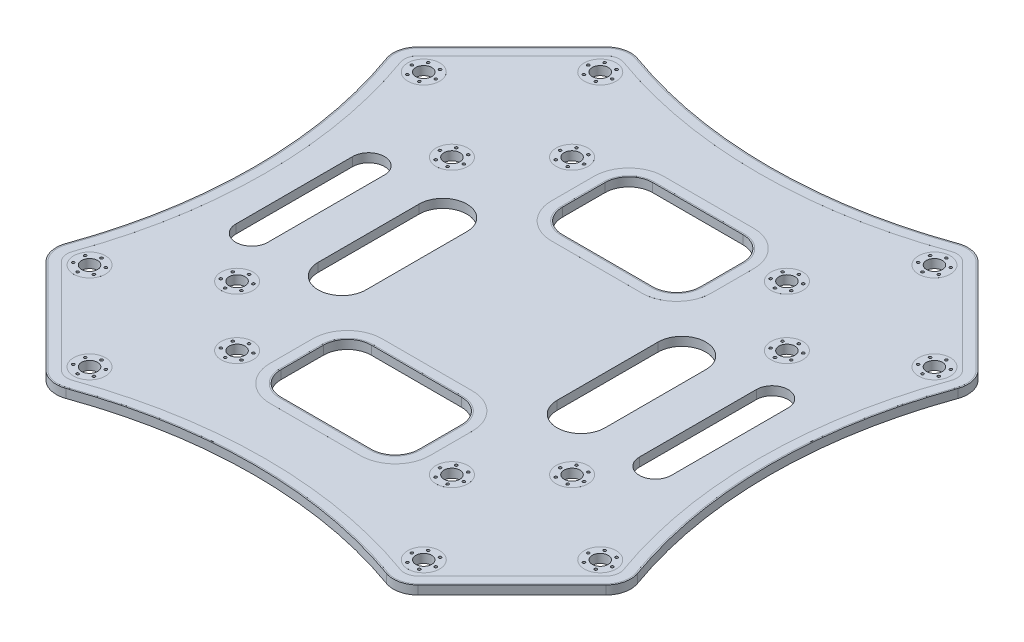
from build123d import *

# Parameters (mm, degrees)
BOSS_EXTRUDE1_DEPTH      = 0.825
BOSS_EXTRUDE1_DEPTH_BACK = 0.825
CUT_EXTRUDE1_DEPTH       = 1.65
SKETCH3_R                = 1.5
CUT_EXTRUDE2_DEPTH       = 1.65
SKETCH4_R                = 3
SKETCH4_R_2              = 1.5
SKETCH4_R_3              = 0.25
BOSS_EXTRUDE2_DEPTH      = 0.001
SKETCH5_R                = 0.25
CUT_EXTRUDE3_DEPTH       = 1.65


with BuildPart() as part:
    # Sketch1 → Boss-Extrude1 (new, two sides)
    with BuildSketch(Plane(origin=(0, 0, 0), x_dir=(1, 0, 0), z_dir=(0, 1, 0))) as boss_extrude1_sk:
        with BuildLine():
            Line((35.046361717, 52.705589829), (52.705589829, 35.046361717))
            ThreePointArc((52.705589829, 35.046361717), (53.961944938, 32.762265708), (53.8, 30.160478519))
            ThreePointArc((53.8, 30.160478519), (48.55, 0), (53.8, -30.160478519))
            ThreePointArc((53.8, -30.160478519), (53.961944938, -32.762265708), (52.705589829, -35.046361717))
            Line((52.705589829, -35.046361717), (35.046361717, -52.705589829))
            ThreePointArc((35.046361717, -52.705589829), (32.762265708, -53.961944938), (30.160478519, -53.8))
            ThreePointArc((30.160478519, -53.8), (0, -48.55), (-30.160478519, -53.8))
            ThreePointArc((-30.160478519, -53.8), (-32.762265708, -53.961944938), (-35.046361717, -52.705589829))
            Line((-35.046361717, -52.705589829), (-52.705589829, -35.046361717))
            ThreePointArc((-52.705589829, -35.046361717), (-53.961944938, -32.762265708), (-53.8, -30.160478519))
            ThreePointArc((-53.8, -30.160478519), (-48.55, 0), (-53.8, 30.160478519))
            ThreePointArc((-53.8, 30.160478519), (-53.961944938, 32.762265708), (-52.705589829, 35.046361717))
            Line((-52.705589829, 35.046361717), (-35.046361717, 52.705589829))
            ThreePointArc((-35.046361717, 52.705589829), (-32.762265708, 53.961944938), (-30.160478519, 53.8))
            ThreePointArc((-30.160478519, 53.8), (0, 48.55), (30.160478519, 53.8))
            ThreePointArc((30.160478519, 53.8), (32.762265708, 53.961944938), (35.046361717, 52.705589829))
        make_face()
    extrude(amount=BOSS_EXTRUDE1_DEPTH)
    extrude(boss_extrude1_sk.sketch, amount=-BOSS_EXTRUDE1_DEPTH_BACK)

    # Sketch2 → Cut-Extrude1 (cut)
    with BuildSketch(Plane(origin=(0, 0.825, 0), x_dir=(1, 0, 0), z_dir=(0, 1, 0))):
        with BuildLine():
            Line((13, 30.5), (13, 22.5))
            ThreePointArc((13, 22.5), (11.681980515, 19.318019485), (8.5, 18))
            Line((8.5, 18), (-8.5, 18))
            ThreePointArc((-8.5, 18), (-11.681980515, 19.318019485), (-13, 22.5))
            Line((-13, 22.5), (-13, 30.5))
            ThreePointArc((-13, 30.5), (-11.681980515, 33.681980515), (-8.5, 35))
            Line((-8.5, 35), (8.5, 35))
            ThreePointArc((8.5, 35), (11.681980515, 33.681980515), (13, 30.5))
        make_face()
        with BuildLine():
            Line((-13, -22.5), (-13, -30.5))
            ThreePointArc((-13, -30.5), (-11.681980515, -33.681980515), (-8.5, -35))
            Line((-8.5, -35), (8.5, -35))
            ThreePointArc((8.5, -35), (11.681980515, -33.681980515), (13, -30.5))
            Line((13, -30.5), (13, -22.5))
            ThreePointArc((13, -22.5), (11.681980515, -19.318019485), (8.5, -18))
            Line((8.5, -18), (-8.5, -18))
            ThreePointArc((-8.5, -18), (-11.681980515, -19.318019485), (-13, -22.5))
        make_face()
        with BuildLine():
            Line((-27, -9.5), (-27, 9.5))
            ThreePointArc((-27, 9.5), (-22.5, 14), (-18, 9.5))
            Line((-18, 9.5), (-18, -9.5))
            ThreePointArc((-18, -9.5), (-22.5, -14), (-27, -9.5))
        make_face()
        with BuildLine():
            Line((18, -9.5), (18, 9.5))
            ThreePointArc((18, 9.5), (22.5, 14), (27, 9.5))
            Line((27, 9.5), (27, -9.5))
            ThreePointArc((27, -9.5), (22.5, -14), (18, -9.5))
        make_face()
        with BuildLine():
            Line((-35, 11), (-35, -11))
            ThreePointArc((-35, -11), (-38, -14), (-41, -11))
            Line((-41, -11), (-41, 11))
            ThreePointArc((-41, 11), (-38, 14), (-35, 11))
        make_face()
        with BuildLine():
            Line((35, 11), (35, -11))
            ThreePointArc((35, -11), (38, -14), (41, -11))
            Line((41, -11), (41, 11))
            ThreePointArc((41, 11), (38, 14), (35, 11))
        make_face()
    extrude(amount=-CUT_EXTRUDE1_DEPTH, mode=Mode.SUBTRACT)

    # Sketch3 → Cut-Extrude2 (cut)
    with BuildSketch(Plane(origin=(0, 0.825, 0), x_dir=(1, 0, 0), z_dir=(0, 1, 0))):
        with Locations(Location((-48.083261121, -31.466251763, 0), (0, 0, 270))):
            Circle(SKETCH3_R)
        with Locations(Location((-31.466251763, -48.083261121, 0), (0, 0, 270))):
            Circle(SKETCH3_R)
        with Locations(Location((31.466251763, -48.083261121, 0), (0, 0, 270))):
            Circle(SKETCH3_R)
        with Locations(Location((48.083261121, -31.466251763, 0), (0, 0, 270))):
            Circle(SKETCH3_R)
        with Locations(Location((48.083261121, 31.466251763, 0), (0, 0, 270))):
            Circle(SKETCH3_R)
        with Locations(Location((31.466251763, 48.083261121, 0), (0, 0, 270))):
            Circle(SKETCH3_R)
        with Locations(Location((-31.466251763, 48.083261121, 0), (0, 0, 270))):
            Circle(SKETCH3_R)
        with Locations(Location((-48.083261121, 31.466251763, 0), (0, 0, 270))):
            Circle(SKETCH3_R)
        with Locations(Location((-31.540291459, -20.22658296, 0), (0, 0, 270))):
            Circle(SKETCH3_R)
        with Locations(Location((-20.22658296, -31.540291459, 0), (0, 0, 270))):
            Circle(SKETCH3_R)
        with Locations(Location((-31.540291459, 20.22658296, 0), (0, 0, 270))):
            Circle(SKETCH3_R)
        with Locations(Location((-20.22658296, 31.540291459, 0), (0, 0, 270))):
            Circle(SKETCH3_R)
        with Locations(Location((20.22658296, 31.540291459, 0), (0, 0, 270))):
            Circle(SKETCH3_R)
        with Locations(Location((31.540291459, 20.22658296, 0), (0, 0, 270))):
            Circle(SKETCH3_R)
        with Locations(Location((31.540291459, -20.22658296, 0), (0, 0, 270))):
            Circle(SKETCH3_R)
        with Locations(Location((20.22658296, -31.540291459, 0), (0, 0, 270))):
            Circle(SKETCH3_R)
    extrude(amount=-CUT_EXTRUDE2_DEPTH, mode=Mode.SUBTRACT)

    # Sketch4 → Boss-Extrude2 (add)
    with BuildSketch(Plane(origin=(0, 0.825, 0), x_dir=(1, 0, 0), z_dir=(0, 1, 0))):
        with BuildLine():
            Line((34.869585021, -52.528813133), (52.528813133, -34.869585021))
            ThreePointArc((52.528813133, -34.869585021), (53.71799007, -32.707621199), (53.564704439, -30.244953362))
            ThreePointArc((53.564704439, -30.244953362), (48.3, 0), (53.564704439, 30.244953362))
            ThreePointArc((53.564704439, 30.244953362), (53.71799007, 32.707621199), (52.528813133, 34.869585021))
            Line((52.528813133, 34.869585021), (34.869585021, 52.528813133))
            ThreePointArc((34.869585021, 52.528813133), (32.707621199, 53.71799007), (30.244953362, 53.564704439))
            ThreePointArc((30.244953362, 53.564704439), (0, 48.3), (-30.244953362, 53.564704439))
            ThreePointArc((-30.244953362, 53.564704439), (-32.707621199, 53.71799007), (-34.869585021, 52.528813133))
            Line((-34.869585021, 52.528813133), (-52.528813133, 34.869585021))
            ThreePointArc((-52.528813133, 34.869585021), (-53.71799007, 32.707621199), (-53.564704439, 30.244953362))
            ThreePointArc((-53.564704439, 30.244953362), (-48.3, 0), (-53.564704439, -30.244953362))
            ThreePointArc((-53.564704439, -30.244953362), (-53.71799007, -32.707621199), (-52.528813133, -34.869585021))
            Line((-52.528813133, -34.869585021), (-34.869585021, -52.528813133))
            ThreePointArc((-34.869585021, -52.528813133), (-32.707621199, -53.71799007), (-30.244953362, -53.564704439))
            ThreePointArc((-30.244953362, -53.564704439), (0, -48.3), (30.244953362, -53.564704439))
            ThreePointArc((30.244953362, -53.564704439), (32.707621199, -53.71799007), (34.869585021, -52.528813133))
        make_face()
        with BuildLine():
            Line((-51.256020927, 33.596792815), (-33.596792815, 51.256020927))
            ThreePointArc((-33.596792815, 51.256020927), (-32.314180733, 51.961515021), (-30.853172233, 51.870576403))
            ThreePointArc((-30.853172233, 51.870576403), (0, 46.5), (30.853172233, 51.870576403))
            ThreePointArc((30.853172233, 51.870576403), (32.314180733, 51.961515021), (33.596792815, 51.256020927))
            Line((33.596792815, 51.256020927), (51.256020927, 33.596792815))
            ThreePointArc((51.256020927, 33.596792815), (51.961515021, 32.314180733), (51.870576403, 30.853172233))
            ThreePointArc((51.870576403, 30.853172233), (46.5, 0), (51.870576403, -30.853172233))
            ThreePointArc((51.870576403, -30.853172233), (51.961515021, -32.314180733), (51.256020927, -33.596792815))
            Line((51.256020927, -33.596792815), (33.596792815, -51.256020927))
            ThreePointArc((33.596792815, -51.256020927), (32.314180733, -51.961515021), (30.853172233, -51.870576403))
            ThreePointArc((30.853172233, -51.870576403), (0, -46.5), (-30.853172233, -51.870576403))
            ThreePointArc((-30.853172233, -51.870576403), (-32.314180733, -51.961515021), (-33.596792815, -51.256020927))
            Line((-33.596792815, -51.256020927), (-51.256020927, -33.596792815))
            ThreePointArc((-51.256020927, -33.596792815), (-51.961515021, -32.314180733), (-51.870576403, -30.853172233))
            ThreePointArc((-51.870576403, -30.853172233), (-46.5, 0), (-51.870576403, 30.853172233))
            ThreePointArc((-51.870576403, 30.853172233), (-51.961515021, 32.314180733), (-51.256020927, 33.596792815))
        make_face(mode=Mode.SUBTRACT)
        with BuildLine():
            Line((15.05, 30.5), (15.05, 22.5))
            ThreePointArc((15.05, 22.5), (13.131549417, 17.868450583), (8.5, 15.95))
            Line((8.5, 15.95), (-8.5, 15.95))
            ThreePointArc((-8.5, 15.95), (-13.131549417, 17.868450583), (-15.05, 22.5))
            Line((-15.05, 22.5), (-15.05, 30.5))
            ThreePointArc((-15.05, 30.5), (-13.131549417, 35.131549417), (-8.5, 37.05))
            Line((-8.5, 37.05), (8.5, 37.05))
            ThreePointArc((8.5, 37.05), (13.131549417, 35.131549417), (15.05, 30.5))
        make_face()
        with BuildLine():
            Line((-8.5, 17.75), (8.5, 17.75))
            ThreePointArc((8.5, 17.75), (11.858757211, 19.141242789), (13.25, 22.5))
            Line((13.25, 22.5), (13.25, 30.5))
            ThreePointArc((13.25, 30.5), (11.858757211, 33.858757211), (8.5, 35.25))
            Line((8.5, 35.25), (-8.5, 35.25))
            ThreePointArc((-8.5, 35.25), (-11.858757211, 33.858757211), (-13.25, 30.5))
            Line((-13.25, 30.5), (-13.25, 22.5))
            ThreePointArc((-13.25, 22.5), (-11.858757211, 19.141242789), (-8.5, 17.75))
        make_face(mode=Mode.SUBTRACT)
        with BuildLine():
            Line((15.05, -30.5), (15.05, -22.5))
            ThreePointArc((15.05, -22.5), (13.131549417, -17.868450583), (8.5, -15.95))
            Line((8.5, -15.95), (-8.5, -15.95))
            ThreePointArc((-8.5, -15.95), (-13.131549417, -17.868450583), (-15.05, -22.5))
            Line((-15.05, -22.5), (-15.05, -30.5))
            ThreePointArc((-15.05, -30.5), (-13.131549417, -35.131549417), (-8.5, -37.05))
            Line((-8.5, -37.05), (8.5, -37.05))
            ThreePointArc((8.5, -37.05), (13.131549417, -35.131549417), (15.05, -30.5))
        make_face()
        with BuildLine():
            Line((13.25, -30.5), (13.25, -22.5))
            ThreePointArc((13.25, -22.5), (11.858757211, -19.141242789), (8.5, -17.75))
            Line((8.5, -17.75), (-8.5, -17.75))
            ThreePointArc((-8.5, -17.75), (-11.858757211, -19.141242789), (-13.25, -22.5))
            Line((-13.25, -22.5), (-13.25, -30.5))
            ThreePointArc((-13.25, -30.5), (-11.858757211, -33.858757211), (-8.5, -35.25))
            Line((-8.5, -35.25), (8.5, -35.25))
            ThreePointArc((8.5, -35.25), (11.858757211, -33.858757211), (13.25, -30.5))
        make_face(mode=Mode.SUBTRACT)
        with Locations(Location((31.466251763, -48.083261121, 0), (0, 0, 270))):
            Circle(SKETCH4_R)
        with Locations(Location((31.466251763, -48.083261121, 0), (0, 0, 270))):
            Circle(SKETCH4_R_2, mode=Mode.SUBTRACT)
        with Locations(Location((30.341251763, -50.031818279, 0), (0, 0, 270))):
            Circle(SKETCH4_R_3, mode=Mode.SUBTRACT)
        with Locations(Location((29.216251763, -48.083261121, 0), (0, 0, 270))):
            Circle(SKETCH4_R_3, mode=Mode.SUBTRACT)
        with Locations(Location((30.341251763, -46.134703962, 0), (0, 0, 270))):
            Circle(SKETCH4_R_3, mode=Mode.SUBTRACT)
        with Locations(Location((32.591251763, -46.134703962, 0), (0, 0, 270))):
            Circle(SKETCH4_R_3, mode=Mode.SUBTRACT)
        with Locations(Location((33.716251763, -48.083261121, 0), (0, 0, 270))):
            Circle(SKETCH4_R_3, mode=Mode.SUBTRACT)
        with Locations(Location((32.591251763, -50.031818279, 0), (0, 0, 270))):
            Circle(SKETCH4_R_3, mode=Mode.SUBTRACT)
        with Locations(Location((48.083261121, -31.466251763, 0), (0, 0, 270))):
            Circle(SKETCH4_R)
        with Locations(Location((48.083261121, -31.466251763, 0), (0, 0, 270))):
            Circle(SKETCH4_R_2, mode=Mode.SUBTRACT)
        with Locations(Location((46.958261121, -33.414808921, 0), (0, 0, 270))):
            Circle(SKETCH4_R_3, mode=Mode.SUBTRACT)
        with Locations(Location((45.833261121, -31.466251763, 0), (0, 0, 270))):
            Circle(SKETCH4_R_3, mode=Mode.SUBTRACT)
        with Locations(Location((46.958261121, -29.517694604, 0), (0, 0, 270))):
            Circle(SKETCH4_R_3, mode=Mode.SUBTRACT)
        with Locations(Location((49.208261121, -29.517694604, 0), (0, 0, 270))):
            Circle(SKETCH4_R_3, mode=Mode.SUBTRACT)
        with Locations(Location((50.333261121, -31.466251763, 0), (0, 0, 270))):
            Circle(SKETCH4_R_3, mode=Mode.SUBTRACT)
        with Locations(Location((49.208261121, -33.414808921, 0), (0, 0, 270))):
            Circle(SKETCH4_R_3, mode=Mode.SUBTRACT)
        with Locations(Location((31.540291459, -20.22658296, 0), (0, 0, 270))):
            Circle(SKETCH4_R)
        with Locations(Location((31.540291459, -20.22658296, 0), (0, 0, 270))):
            Circle(SKETCH4_R_2, mode=Mode.SUBTRACT)
        with Locations(Location((30.415291459, -22.175140119, 0), (0, 0, 270))):
            Circle(SKETCH4_R_3, mode=Mode.SUBTRACT)
        with Locations(Location((29.290291459, -20.22658296, 0), (0, 0, 270))):
            Circle(SKETCH4_R_3, mode=Mode.SUBTRACT)
        with Locations(Location((30.415291459, -18.278025802, 0), (0, 0, 270))):
            Circle(SKETCH4_R_3, mode=Mode.SUBTRACT)
        with Locations(Location((32.665291459, -18.278025802, 0), (0, 0, 270))):
            Circle(SKETCH4_R_3, mode=Mode.SUBTRACT)
        with Locations(Location((33.790291459, -20.22658296, 0), (0, 0, 270))):
            Circle(SKETCH4_R_3, mode=Mode.SUBTRACT)
        with Locations(Location((32.665291459, -22.175140119, 0), (0, 0, 270))):
            Circle(SKETCH4_R_3, mode=Mode.SUBTRACT)
        with Locations(Location((20.22658296, -31.540291459, 0), (0, 0, 270))):
            Circle(SKETCH4_R)
        with Locations(Location((20.22658296, -31.540291459, 0), (0, 0, 270))):
            Circle(SKETCH4_R_2, mode=Mode.SUBTRACT)
        with Locations(Location((19.10158296, -33.488848618, 0), (0, 0, 270))):
            Circle(SKETCH4_R_3, mode=Mode.SUBTRACT)
        with Locations(Location((21.35158296, -33.488848618, 0), (0, 0, 270))):
            Circle(SKETCH4_R_3, mode=Mode.SUBTRACT)
        with Locations(Location((22.47658296, -31.540291459, 0), (0, 0, 270))):
            Circle(SKETCH4_R_3, mode=Mode.SUBTRACT)
        with Locations(Location((21.35158296, -29.591734301, 0), (0, 0, 270))):
            Circle(SKETCH4_R_3, mode=Mode.SUBTRACT)
        with Locations(Location((19.10158296, -29.591734301, 0), (0, 0, 270))):
            Circle(SKETCH4_R_3, mode=Mode.SUBTRACT)
        with Locations(Location((17.97658296, -31.540291459, 0), (0, 0, 270))):
            Circle(SKETCH4_R_3, mode=Mode.SUBTRACT)
        with Locations(Location((31.540291459, 20.22658296, 0), (0, 0, 270))):
            Circle(SKETCH4_R)
        with Locations(Location((31.540291459, 20.22658296, 0), (0, 0, 270))):
            Circle(SKETCH4_R_2, mode=Mode.SUBTRACT)
        with Locations(Location((29.591734301, 21.35158296, 0), (0, 0, 270))):
            Circle(SKETCH4_R_3, mode=Mode.SUBTRACT)
        with Locations(Location((29.591734301, 19.10158296, 0), (0, 0, 270))):
            Circle(SKETCH4_R_3, mode=Mode.SUBTRACT)
        with Locations(Location((31.540291459, 17.97658296, 0), (0, 0, 270))):
            Circle(SKETCH4_R_3, mode=Mode.SUBTRACT)
        with Locations(Location((33.488848618, 19.10158296, 0), (0, 0, 270))):
            Circle(SKETCH4_R_3, mode=Mode.SUBTRACT)
        with Locations(Location((33.488848618, 21.35158296, 0), (0, 0, 270))):
            Circle(SKETCH4_R_3, mode=Mode.SUBTRACT)
        with Locations(Location((31.540291459, 22.47658296, 0), (0, 0, 270))):
            Circle(SKETCH4_R_3, mode=Mode.SUBTRACT)
        with Locations(Location((48.083261121, 31.466251763, 0), (0, 0, 270))):
            Circle(SKETCH4_R)
        with Locations(Location((48.083261121, 31.466251763, 0), (0, 0, 270))):
            Circle(SKETCH4_R_2, mode=Mode.SUBTRACT)
        with Locations(Location((48.083261121, 29.216251763, 0), (0, 0, 270))):
            Circle(SKETCH4_R_3, mode=Mode.SUBTRACT)
        with Locations(Location((46.134703962, 30.341251763, 0), (0, 0, 270))):
            Circle(SKETCH4_R_3, mode=Mode.SUBTRACT)
        with Locations(Location((50.031818279, 30.341251763, 0), (0, 0, 270))):
            Circle(SKETCH4_R_3, mode=Mode.SUBTRACT)
        with Locations(Location((50.031818279, 32.591251763, 0), (0, 0, 270))):
            Circle(SKETCH4_R_3, mode=Mode.SUBTRACT)
        with Locations(Location((48.083261121, 33.716251763, 0), (0, 0, 270))):
            Circle(SKETCH4_R_3, mode=Mode.SUBTRACT)
        with Locations(Location((46.134703962, 32.591251763, 0), (0, 0, 270))):
            Circle(SKETCH4_R_3, mode=Mode.SUBTRACT)
        with Locations(Location((31.466251763, 48.083261121, 0), (0, 0, 270))):
            Circle(SKETCH4_R)
        with Locations(Location((31.466251763, 48.083261121, 0), (0, 0, 270))):
            Circle(SKETCH4_R_2, mode=Mode.SUBTRACT)
        with Locations(Location((31.466251763, 45.833261121, 0), (0, 0, 270))):
            Circle(SKETCH4_R_3, mode=Mode.SUBTRACT)
        with Locations(Location((29.517694604, 46.958261121, 0), (0, 0, 270))):
            Circle(SKETCH4_R_3, mode=Mode.SUBTRACT)
        with Locations(Location((29.517694604, 49.208261121, 0), (0, 0, 270))):
            Circle(SKETCH4_R_3, mode=Mode.SUBTRACT)
        with Locations(Location((31.466251763, 50.333261121, 0), (0, 0, 270))):
            Circle(SKETCH4_R_3, mode=Mode.SUBTRACT)
        with Locations(Location((33.414808921, 49.208261121, 0), (0, 0, 270))):
            Circle(SKETCH4_R_3, mode=Mode.SUBTRACT)
        with Locations(Location((33.414808921, 46.958261121, 0), (0, 0, 270))):
            Circle(SKETCH4_R_3, mode=Mode.SUBTRACT)
        with Locations(Location((20.22658296, 31.540291459, 0), (0, 0, 270))):
            Circle(SKETCH4_R)
        with Locations(Location((20.22658296, 31.540291459, 0), (0, 0, 270))):
            Circle(SKETCH4_R_2, mode=Mode.SUBTRACT)
        with Locations(Location((20.22658296, 29.290291459, 0), (0, 0, 270))):
            Circle(SKETCH4_R_3, mode=Mode.SUBTRACT)
        with Locations(Location((22.175140119, 30.415291459, 0), (0, 0, 270))):
            Circle(SKETCH4_R_3, mode=Mode.SUBTRACT)
        with Locations(Location((22.175140119, 32.665291459, 0), (0, 0, 270))):
            Circle(SKETCH4_R_3, mode=Mode.SUBTRACT)
        with Locations(Location((18.278025802, 30.415291459, 0), (0, 0, 270))):
            Circle(SKETCH4_R_3, mode=Mode.SUBTRACT)
        with Locations(Location((18.278025802, 32.665291459, 0), (0, 0, 270))):
            Circle(SKETCH4_R_3, mode=Mode.SUBTRACT)
        with Locations(Location((20.22658296, 33.790291459, 0), (0, 0, 270))):
            Circle(SKETCH4_R_3, mode=Mode.SUBTRACT)
        with Locations(Location((-31.466251763, 48.083261121, 0), (0, 0, 270))):
            Circle(SKETCH4_R)
        with Locations(Location((-31.466251763, 48.083261121, 0), (0, 0, 270))):
            Circle(SKETCH4_R_2, mode=Mode.SUBTRACT)
        with Locations(Location((-32.591251763, 46.134703962, 0), (0, 0, 270))):
            Circle(SKETCH4_R_3, mode=Mode.SUBTRACT)
        with Locations(Location((-33.716251763, 48.083261121, 0), (0, 0, 270))):
            Circle(SKETCH4_R_3, mode=Mode.SUBTRACT)
        with Locations(Location((-32.591251763, 50.031818279, 0), (0, 0, 270))):
            Circle(SKETCH4_R_3, mode=Mode.SUBTRACT)
        with Locations(Location((-30.341251763, 50.031818279, 0), (0, 0, 270))):
            Circle(SKETCH4_R_3, mode=Mode.SUBTRACT)
        with Locations(Location((-29.216251763, 48.083261121, 0), (0, 0, 270))):
            Circle(SKETCH4_R_3, mode=Mode.SUBTRACT)
        with Locations(Location((-30.341251763, 46.134703962, 0), (0, 0, 270))):
            Circle(SKETCH4_R_3, mode=Mode.SUBTRACT)
        with Locations(Location((-20.22658296, 31.540291459, 0), (0, 0, 270))):
            Circle(SKETCH4_R)
        with Locations(Location((-20.22658296, 31.540291459, 0), (0, 0, 270))):
            Circle(SKETCH4_R_2, mode=Mode.SUBTRACT)
        with Locations(Location((-19.10158296, 29.591734301, 0), (0, 0, 270))):
            Circle(SKETCH4_R_3, mode=Mode.SUBTRACT)
        with Locations(Location((-21.35158296, 29.591734301, 0), (0, 0, 270))):
            Circle(SKETCH4_R_3, mode=Mode.SUBTRACT)
        with Locations(Location((-22.47658296, 31.540291459, 0), (0, 0, 270))):
            Circle(SKETCH4_R_3, mode=Mode.SUBTRACT)
        with Locations(Location((-21.35158296, 33.488848618, 0), (0, 0, 270))):
            Circle(SKETCH4_R_3, mode=Mode.SUBTRACT)
        with Locations(Location((-19.10158296, 33.488848618, 0), (0, 0, 270))):
            Circle(SKETCH4_R_3, mode=Mode.SUBTRACT)
        with Locations(Location((-17.97658296, 31.540291459, 0), (0, 0, 270))):
            Circle(SKETCH4_R_3, mode=Mode.SUBTRACT)
        with Locations(Location((-31.540291459, 20.22658296, 0), (0, 0, 270))):
            Circle(SKETCH4_R)
        with Locations(Location((-31.540291459, 20.22658296, 0), (0, 0, 270))):
            Circle(SKETCH4_R_2, mode=Mode.SUBTRACT)
        with Locations(Location((-32.665291459, 18.278025802, 0), (0, 0, 270))):
            Circle(SKETCH4_R_3, mode=Mode.SUBTRACT)
        with Locations(Location((-33.790291459, 20.22658296, 0), (0, 0, 270))):
            Circle(SKETCH4_R_3, mode=Mode.SUBTRACT)
        with Locations(Location((-32.665291459, 22.175140119, 0), (0, 0, 270))):
            Circle(SKETCH4_R_3, mode=Mode.SUBTRACT)
        with Locations(Location((-30.415291459, 22.175140119, 0), (0, 0, 270))):
            Circle(SKETCH4_R_3, mode=Mode.SUBTRACT)
        with Locations(Location((-29.290291459, 20.22658296, 0), (0, 0, 270))):
            Circle(SKETCH4_R_3, mode=Mode.SUBTRACT)
        with Locations(Location((-30.415291459, 18.278025802, 0), (0, 0, 270))):
            Circle(SKETCH4_R_3, mode=Mode.SUBTRACT)
        with Locations(Location((-48.083261121, 31.466251763, 0), (0, 0, 270))):
            Circle(SKETCH4_R)
        with Locations(Location((-48.083261121, 31.466251763, 0), (0, 0, 270))):
            Circle(SKETCH4_R_2, mode=Mode.SUBTRACT)
        with Locations(Location((-46.958261121, 29.517694604, 0), (0, 0, 270))):
            Circle(SKETCH4_R_3, mode=Mode.SUBTRACT)
        with Locations(Location((-45.833261121, 31.466251763, 0), (0, 0, 270))):
            Circle(SKETCH4_R_3, mode=Mode.SUBTRACT)
        with Locations(Location((-46.958261121, 33.414808921, 0), (0, 0, 270))):
            Circle(SKETCH4_R_3, mode=Mode.SUBTRACT)
        with Locations(Location((-49.208261121, 33.414808921, 0), (0, 0, 270))):
            Circle(SKETCH4_R_3, mode=Mode.SUBTRACT)
        with Locations(Location((-50.333261121, 31.466251763, 0), (0, 0, 270))):
            Circle(SKETCH4_R_3, mode=Mode.SUBTRACT)
        with Locations(Location((-49.208261121, 29.517694604, 0), (0, 0, 270))):
            Circle(SKETCH4_R_3, mode=Mode.SUBTRACT)
        with Locations(Location((-20.22658296, -31.540291459, 0), (0, 0, 270))):
            Circle(SKETCH4_R)
        with Locations(Location((-20.22658296, -31.540291459, 0), (0, 0, 270))):
            Circle(SKETCH4_R_2, mode=Mode.SUBTRACT)
        with Locations(Location((-20.22658296, -33.790291459, 0), (0, 0, 270))):
            Circle(SKETCH4_R_3, mode=Mode.SUBTRACT)
        with Locations(Location((-18.278025802, -32.665291459, 0), (0, 0, 270))):
            Circle(SKETCH4_R_3, mode=Mode.SUBTRACT)
        with Locations(Location((-18.278025802, -30.415291459, 0), (0, 0, 270))):
            Circle(SKETCH4_R_3, mode=Mode.SUBTRACT)
        with Locations(Location((-20.22658296, -29.290291459, 0), (0, 0, 270))):
            Circle(SKETCH4_R_3, mode=Mode.SUBTRACT)
        with Locations(Location((-22.175140119, -30.415291459, 0), (0, 0, 270))):
            Circle(SKETCH4_R_3, mode=Mode.SUBTRACT)
        with Locations(Location((-22.175140119, -32.665291459, 0), (0, 0, 270))):
            Circle(SKETCH4_R_3, mode=Mode.SUBTRACT)
        with Locations(Location((-31.540291459, -20.22658296, 0), (0, 0, 270))):
            Circle(SKETCH4_R)
        with Locations(Location((-31.540291459, -20.22658296, 0), (0, 0, 270))):
            Circle(SKETCH4_R_2, mode=Mode.SUBTRACT)
        with Locations(Location((-31.540291459, -22.47658296, 0), (0, 0, 270))):
            Circle(SKETCH4_R_3, mode=Mode.SUBTRACT)
        with Locations(Location((-29.591734301, -21.35158296, 0), (0, 0, 270))):
            Circle(SKETCH4_R_3, mode=Mode.SUBTRACT)
        with Locations(Location((-29.591734301, -19.10158296, 0), (0, 0, 270))):
            Circle(SKETCH4_R_3, mode=Mode.SUBTRACT)
        with Locations(Location((-31.540291459, -17.97658296, 0), (0, 0, 270))):
            Circle(SKETCH4_R_3, mode=Mode.SUBTRACT)
        with Locations(Location((-33.488848618, -19.10158296, 0), (0, 0, 270))):
            Circle(SKETCH4_R_3, mode=Mode.SUBTRACT)
        with Locations(Location((-33.488848618, -21.35158296, 0), (0, 0, 270))):
            Circle(SKETCH4_R_3, mode=Mode.SUBTRACT)
        with Locations(Location((-48.083261121, -31.466251763, 0), (0, 0, 270))):
            Circle(SKETCH4_R)
        with Locations(Location((-48.083261121, -31.466251763, 0), (0, 0, 270))):
            Circle(SKETCH4_R_2, mode=Mode.SUBTRACT)
        with Locations(Location((-48.083261121, -33.716251763, 0), (0, 0, 270))):
            Circle(SKETCH4_R_3, mode=Mode.SUBTRACT)
        with Locations(Location((-46.134703962, -32.591251763, 0), (0, 0, 270))):
            Circle(SKETCH4_R_3, mode=Mode.SUBTRACT)
        with Locations(Location((-46.134703962, -30.341251763, 0), (0, 0, 270))):
            Circle(SKETCH4_R_3, mode=Mode.SUBTRACT)
        with Locations(Location((-48.083261121, -29.216251763, 0), (0, 0, 270))):
            Circle(SKETCH4_R_3, mode=Mode.SUBTRACT)
        with Locations(Location((-50.031818279, -30.341251763, 0), (0, 0, 270))):
            Circle(SKETCH4_R_3, mode=Mode.SUBTRACT)
        with Locations(Location((-50.031818279, -32.591251763, 0), (0, 0, 270))):
            Circle(SKETCH4_R_3, mode=Mode.SUBTRACT)
        with Locations(Location((-31.466251763, -48.083261121, 0), (0, 0, 270))):
            Circle(SKETCH4_R)
        with Locations(Location((-31.466251763, -48.083261121, 0), (0, 0, 270))):
            Circle(SKETCH4_R_2, mode=Mode.SUBTRACT)
        with Locations(Location((-31.466251763, -50.333261121, 0), (0, 0, 270))):
            Circle(SKETCH4_R_3, mode=Mode.SUBTRACT)
        with Locations(Location((-29.517694604, -49.208261121, 0), (0, 0, 270))):
            Circle(SKETCH4_R_3, mode=Mode.SUBTRACT)
        with Locations(Location((-29.517694604, -46.958261121, 0), (0, 0, 270))):
            Circle(SKETCH4_R_3, mode=Mode.SUBTRACT)
        with Locations(Location((-31.466251763, -45.833261121, 0), (0, 0, 270))):
            Circle(SKETCH4_R_3, mode=Mode.SUBTRACT)
        with Locations(Location((-33.414808921, -46.958261121, 0), (0, 0, 270))):
            Circle(SKETCH4_R_3, mode=Mode.SUBTRACT)
        with Locations(Location((-33.414808921, -49.208261121, 0), (0, 0, 270))):
            Circle(SKETCH4_R_3, mode=Mode.SUBTRACT)
    boss_extrude2 = extrude(amount=BOSS_EXTRUDE2_DEPTH)

    # Mirror2: Boss-Extrude2 across plane
    add(boss_extrude2.mirror(Plane.ZX))

    # Sketch5 → Cut-Extrude3 (cut)
    with BuildSketch(Plane(origin=(0, 0.825, 0), x_dir=(1, 0, 0), z_dir=(0, 1, 0))):
        with Locations(Location((-31.466251763, -45.833261121, 0), (0, 0, 270))):
            Circle(SKETCH5_R)
        with Locations(Location((-29.517694604, -46.958261121, 0), (0, 0, 270))):
            Circle(SKETCH5_R)
        with Locations(Location((-29.517694604, -49.208261121, 0), (0, 0, 270))):
            Circle(SKETCH5_R)
        with Locations(Location((-31.466251763, -50.333261121, 0), (0, 0, 270))):
            Circle(SKETCH5_R)
        with Locations(Location((-33.414808921, -49.208261121, 0), (0, 0, 270))):
            Circle(SKETCH5_R)
        with Locations(Location((-33.414808921, -46.958261121, 0), (0, 0, 270))):
            Circle(SKETCH5_R)
        with Locations(Location((-48.083261121, -33.716251763, 0), (0, 0, 270))):
            Circle(SKETCH5_R)
        with Locations(Location((-50.031818279, -32.591251763, 0), (0, 0, 270))):
            Circle(SKETCH5_R)
        with Locations(Location((-50.031818279, -30.341251763, 0), (0, 0, 270))):
            Circle(SKETCH5_R)
        with Locations(Location((-48.083261121, -29.216251763, 0), (0, 0, 270))):
            Circle(SKETCH5_R)
        with Locations(Location((-46.134703962, -30.341251763, 0), (0, 0, 270))):
            Circle(SKETCH5_R)
        with Locations(Location((-46.134703962, -32.591251763, 0), (0, 0, 270))):
            Circle(SKETCH5_R)
        with Locations(Location((-33.488848618, -21.35158296, 0), (0, 0, 270))):
            Circle(SKETCH5_R)
        with Locations(Location((-33.488848618, -19.10158296, 0), (0, 0, 270))):
            Circle(SKETCH5_R)
        with Locations(Location((-31.540291459, -17.97658296, 0), (0, 0, 270))):
            Circle(SKETCH5_R)
        with Locations(Location((-29.591734301, -19.10158296, 0), (0, 0, 270))):
            Circle(SKETCH5_R)
        with Locations(Location((-29.591734301, -21.35158296, 0), (0, 0, 270))):
            Circle(SKETCH5_R)
        with Locations(Location((-31.540291459, -22.47658296, 0), (0, 0, 270))):
            Circle(SKETCH5_R)
        with Locations(Location((-22.175140119, -30.415291459, 0), (0, 0, 270))):
            Circle(SKETCH5_R)
        with Locations(Location((-22.175140119, -32.665291459, 0), (0, 0, 270))):
            Circle(SKETCH5_R)
        with Locations(Location((-20.22658296, -33.790291459, 0), (0, 0, 270))):
            Circle(SKETCH5_R)
        with Locations(Location((-18.278025802, -32.665291459, 0), (0, 0, 270))):
            Circle(SKETCH5_R)
        with Locations(Location((-18.278025802, -30.415291459, 0), (0, 0, 270))):
            Circle(SKETCH5_R)
        with Locations(Location((-20.22658296, -29.290291459, 0), (0, 0, 270))):
            Circle(SKETCH5_R)
        with Locations(Location((19.10158296, -33.488848618, 0), (0, 0, 270))):
            Circle(SKETCH5_R)
        with Locations(Location((17.97658296, -31.540291459, 0), (0, 0, 270))):
            Circle(SKETCH5_R)
        with Locations(Location((19.10158296, -29.591734301, 0), (0, 0, 270))):
            Circle(SKETCH5_R)
        with Locations(Location((21.35158296, -29.591734301, 0), (0, 0, 270))):
            Circle(SKETCH5_R)
        with Locations(Location((22.47658296, -31.540291459, 0), (0, 0, 270))):
            Circle(SKETCH5_R)
        with Locations(Location((21.35158296, -33.488848618, 0), (0, 0, 270))):
            Circle(SKETCH5_R)
        with Locations(Location((29.290291459, -20.22658296, 0), (0, 0, 270))):
            Circle(SKETCH5_R)
        with Locations(Location((30.415291459, -18.278025802, 0), (0, 0, 270))):
            Circle(SKETCH5_R)
        with Locations(Location((32.665291459, -18.278025802, 0), (0, 0, 270))):
            Circle(SKETCH5_R)
        with Locations(Location((30.415291459, -22.175140119, 0), (0, 0, 270))):
            Circle(SKETCH5_R)
        with Locations(Location((32.665291459, -22.175140119, 0), (0, 0, 270))):
            Circle(SKETCH5_R)
        with Locations(Location((33.790291459, -20.22658296, 0), (0, 0, 270))):
            Circle(SKETCH5_R)
        with Locations(Location((46.958261121, -29.517694604, 0), (0, 0, 270))):
            Circle(SKETCH5_R)
        with Locations(Location((49.208261121, -29.517694604, 0), (0, 0, 270))):
            Circle(SKETCH5_R)
        with Locations(Location((45.833261121, -31.466251763, 0), (0, 0, 270))):
            Circle(SKETCH5_R)
        with Locations(Location((46.958261121, -33.414808921, 0), (0, 0, 270))):
            Circle(SKETCH5_R)
        with Locations(Location((49.208261121, -33.414808921, 0), (0, 0, 270))):
            Circle(SKETCH5_R)
        with Locations(Location((50.333261121, -31.466251763, 0), (0, 0, 270))):
            Circle(SKETCH5_R)
        with Locations(Location((30.341251763, -46.134703962, 0), (0, 0, 270))):
            Circle(SKETCH5_R)
        with Locations(Location((32.591251763, -46.134703962, 0), (0, 0, 270))):
            Circle(SKETCH5_R)
        with Locations(Location((29.216251763, -48.083261121, 0), (0, 0, 270))):
            Circle(SKETCH5_R)
        with Locations(Location((30.341251763, -50.031818279, 0), (0, 0, 270))):
            Circle(SKETCH5_R)
        with Locations(Location((32.591251763, -50.031818279, 0), (0, 0, 270))):
            Circle(SKETCH5_R)
        with Locations(Location((33.716251763, -48.083261121, 0), (0, 0, 270))):
            Circle(SKETCH5_R)
        with Locations(Location((-32.665291459, 18.278025802, 0), (0, 0, 270))):
            Circle(SKETCH5_R)
        with Locations(Location((-33.790291459, 20.22658296, 0), (0, 0, 270))):
            Circle(SKETCH5_R)
        with Locations(Location((-32.665291459, 22.175140119, 0), (0, 0, 270))):
            Circle(SKETCH5_R)
        with Locations(Location((-30.415291459, 22.175140119, 0), (0, 0, 270))):
            Circle(SKETCH5_R)
        with Locations(Location((-29.290291459, 20.22658296, 0), (0, 0, 270))):
            Circle(SKETCH5_R)
        with Locations(Location((-30.415291459, 18.278025802, 0), (0, 0, 270))):
            Circle(SKETCH5_R)
        with Locations(Location((-49.208261121, 29.517694604, 0), (0, 0, 270))):
            Circle(SKETCH5_R)
        with Locations(Location((-50.333261121, 31.466251763, 0), (0, 0, 270))):
            Circle(SKETCH5_R)
        with Locations(Location((-49.208261121, 33.414808921, 0), (0, 0, 270))):
            Circle(SKETCH5_R)
        with Locations(Location((-46.958261121, 33.414808921, 0), (0, 0, 270))):
            Circle(SKETCH5_R)
        with Locations(Location((-45.833261121, 31.466251763, 0), (0, 0, 270))):
            Circle(SKETCH5_R)
        with Locations(Location((-46.958261121, 29.517694604, 0), (0, 0, 270))):
            Circle(SKETCH5_R)
        with Locations(Location((-32.591251763, 46.134703962, 0), (0, 0, 270))):
            Circle(SKETCH5_R)
        with Locations(Location((-33.716251763, 48.083261121, 0), (0, 0, 270))):
            Circle(SKETCH5_R)
        with Locations(Location((-32.591251763, 50.031818279, 0), (0, 0, 270))):
            Circle(SKETCH5_R)
        with Locations(Location((-30.341251763, 50.031818279, 0), (0, 0, 270))):
            Circle(SKETCH5_R)
        with Locations(Location((-29.216251763, 48.083261121, 0), (0, 0, 270))):
            Circle(SKETCH5_R)
        with Locations(Location((-30.341251763, 46.134703962, 0), (0, 0, 270))):
            Circle(SKETCH5_R)
        with Locations(Location((-21.35158296, 29.591734301, 0), (0, 0, 270))):
            Circle(SKETCH5_R)
        with Locations(Location((-22.47658296, 31.540291459, 0), (0, 0, 270))):
            Circle(SKETCH5_R)
        with Locations(Location((-21.35158296, 33.488848618, 0), (0, 0, 270))):
            Circle(SKETCH5_R)
        with Locations(Location((-19.10158296, 33.488848618, 0), (0, 0, 270))):
            Circle(SKETCH5_R)
        with Locations(Location((-17.97658296, 31.540291459, 0), (0, 0, 270))):
            Circle(SKETCH5_R)
        with Locations(Location((-19.10158296, 29.591734301, 0), (0, 0, 270))):
            Circle(SKETCH5_R)
        with Locations(Location((20.22658296, 29.290291459, 0), (0, 0, 270))):
            Circle(SKETCH5_R)
        with Locations(Location((18.278025802, 30.415291459, 0), (0, 0, 270))):
            Circle(SKETCH5_R)
        with Locations(Location((18.278025802, 32.665291459, 0), (0, 0, 270))):
            Circle(SKETCH5_R)
        with Locations(Location((20.22658296, 33.790291459, 0), (0, 0, 270))):
            Circle(SKETCH5_R)
        with Locations(Location((22.175140119, 32.665291459, 0), (0, 0, 270))):
            Circle(SKETCH5_R)
        with Locations(Location((22.175140119, 30.415291459, 0), (0, 0, 270))):
            Circle(SKETCH5_R)
        with Locations(Location((29.591734301, 21.35158296, 0), (0, 0, 270))):
            Circle(SKETCH5_R)
        with Locations(Location((31.540291459, 22.47658296, 0), (0, 0, 270))):
            Circle(SKETCH5_R)
        with Locations(Location((29.591734301, 19.10158296, 0), (0, 0, 270))):
            Circle(SKETCH5_R)
        with Locations(Location((31.540291459, 17.97658296, 0), (0, 0, 270))):
            Circle(SKETCH5_R)
        with Locations(Location((33.488848618, 19.10158296, 0), (0, 0, 270))):
            Circle(SKETCH5_R)
        with Locations(Location((33.488848618, 21.35158296, 0), (0, 0, 270))):
            Circle(SKETCH5_R)
        with Locations(Location((48.083261121, 29.216251763, 0), (0, 0, 270))):
            Circle(SKETCH5_R)
        with Locations(Location((50.031818279, 30.341251763, 0), (0, 0, 270))):
            Circle(SKETCH5_R)
        with Locations(Location((50.031818279, 32.591251763, 0), (0, 0, 270))):
            Circle(SKETCH5_R)
        with Locations(Location((48.083261121, 33.716251763, 0), (0, 0, 270))):
            Circle(SKETCH5_R)
        with Locations(Location((46.134703962, 32.591251763, 0), (0, 0, 270))):
            Circle(SKETCH5_R)
        with Locations(Location((46.134703962, 30.341251763, 0), (0, 0, 270))):
            Circle(SKETCH5_R)
        with Locations(Location((31.466251763, 45.833261121, 0), (0, 0, 270))):
            Circle(SKETCH5_R)
        with Locations(Location((29.517694604, 46.958261121, 0), (0, 0, 270))):
            Circle(SKETCH5_R)
        with Locations(Location((29.517694604, 49.208261121, 0), (0, 0, 270))):
            Circle(SKETCH5_R)
        with Locations(Location((31.466251763, 50.333261121, 0), (0, 0, 270))):
            Circle(SKETCH5_R)
        with Locations(Location((33.414808921, 49.208261121, 0), (0, 0, 270))):
            Circle(SKETCH5_R)
        with Locations(Location((33.414808921, 46.958261121, 0), (0, 0, 270))):
            Circle(SKETCH5_R)
    extrude(amount=-CUT_EXTRUDE3_DEPTH, mode=Mode.SUBTRACT)


solid = part.part
